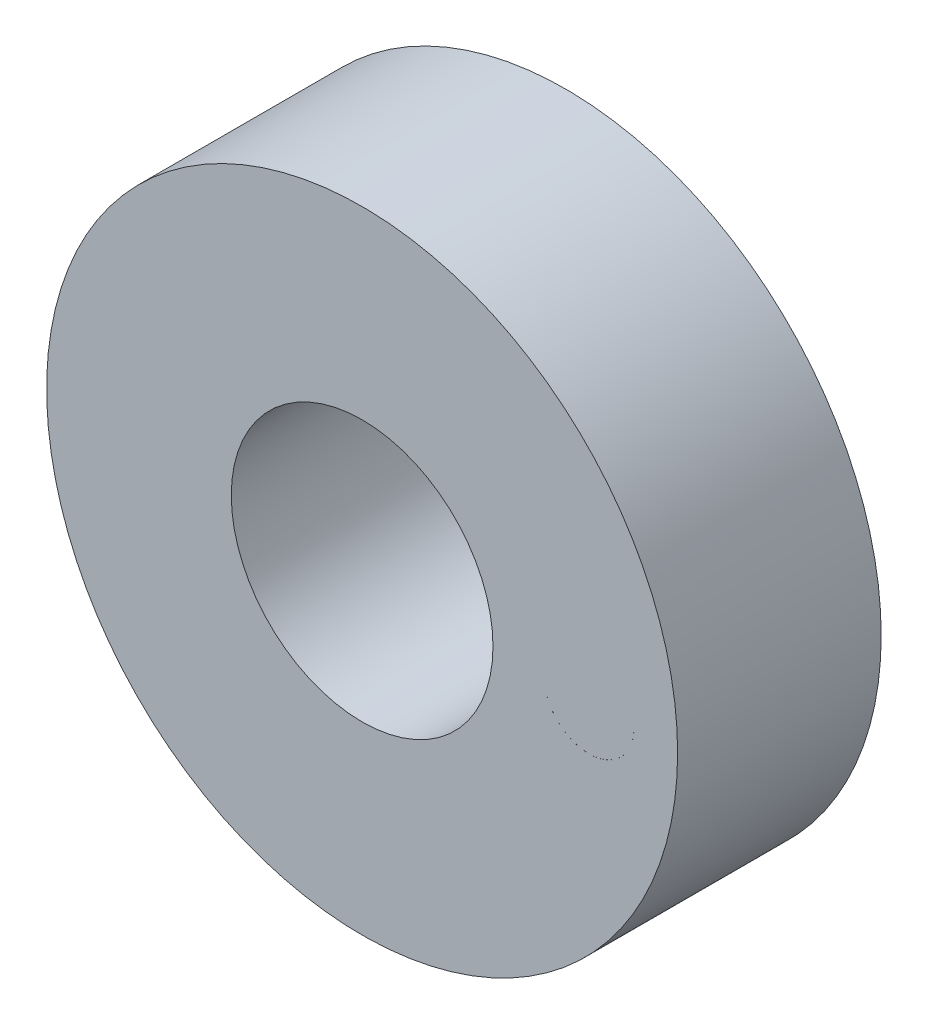
from build123d import *

# Parameters (mm, degrees)
SKETCH1_R           = 10.85
SKETCH1_R_2         = 4.5
SKETCH1_R_3         = 1.55
BOSS_EXTRUDE1_DEPTH = 7
SKETCH2_R           = 1.55
BOSS_EXTRUDE2_DEPTH = 3


with BuildPart() as part:
    # Sketch1 → Boss-Extrude1 (new body)
    with BuildSketch(Plane.XY):
        Circle(SKETCH1_R)
        Circle(SKETCH1_R_2, mode=Mode.SUBTRACT)
        with Locations((-7.8, 0)):
            Circle(SKETCH1_R_3, mode=Mode.SUBTRACT)
        with Locations((0, 7.8)):
            Circle(SKETCH1_R_3, mode=Mode.SUBTRACT)
        with Locations((7.8, 0)):
            Circle(SKETCH1_R_3, mode=Mode.SUBTRACT)
        with Locations((0, -7.8)):
            Circle(SKETCH1_R_3, mode=Mode.SUBTRACT)
    extrude(amount=BOSS_EXTRUDE1_DEPTH)

    # Sketch2 → Boss-Extrude2 (add)
    with BuildSketch(Plane.XY.offset(7)):
        with Locations((0, 7.8)):
            Circle(SKETCH2_R)
        with Locations((-7.8, 0)):
            Circle(SKETCH2_R)
        with Locations((0, -7.8)):
            Circle(SKETCH2_R)
        with Locations((7.799999915, 0.00162894)):
            Circle(SKETCH2_R)
    extrude(amount=-BOSS_EXTRUDE2_DEPTH)


solid = part.part
